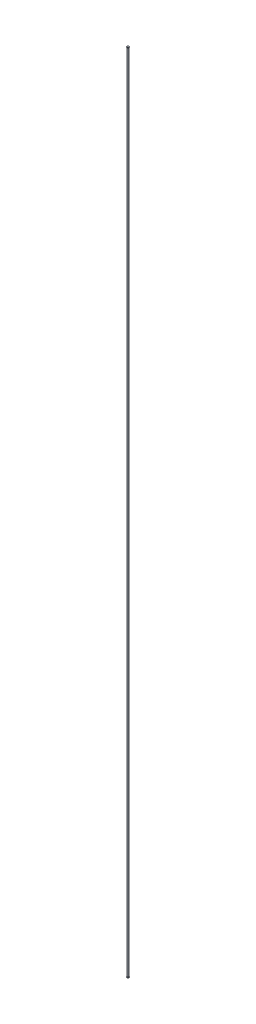
from build123d import *

# Parameters (mm, degrees)
SKETCH1_R           = 6.35
SKETCH1_R_2         = 3.175
BOSS_EXTRUDE1_DEPTH = 7781.036


with BuildPart() as part:
    # Sketch1 → Boss-Extrude1 (new body)
    with BuildSketch(Plane(origin=(0, 0, 0), x_dir=(1, 0, 0), z_dir=(0, 1, 0))):
        Circle(SKETCH1_R)
        Circle(SKETCH1_R_2, mode=Mode.SUBTRACT)
    extrude(amount=BOSS_EXTRUDE1_DEPTH)

    # Sketch2 → Revolve1 (revolve)
    with BuildSketch(Plane(origin=(0, 0, 0), x_dir=(0, 0, -1), z_dir=(1, 0, 0))):
        Polygon((6.35, 7781.036), (10.431701322, 7785.900382214), (8.568534839, 7787.463764522), (3.175, 7781.036), align=None)
    revolve1 = revolve(axis=Axis((0, 8176.570252748, 0), (0, -1, 0)))

    # Mirror1: Revolve1 across plane
    add(revolve1.mirror(Plane.ZX.offset(3890.518)))


solid = part.part
